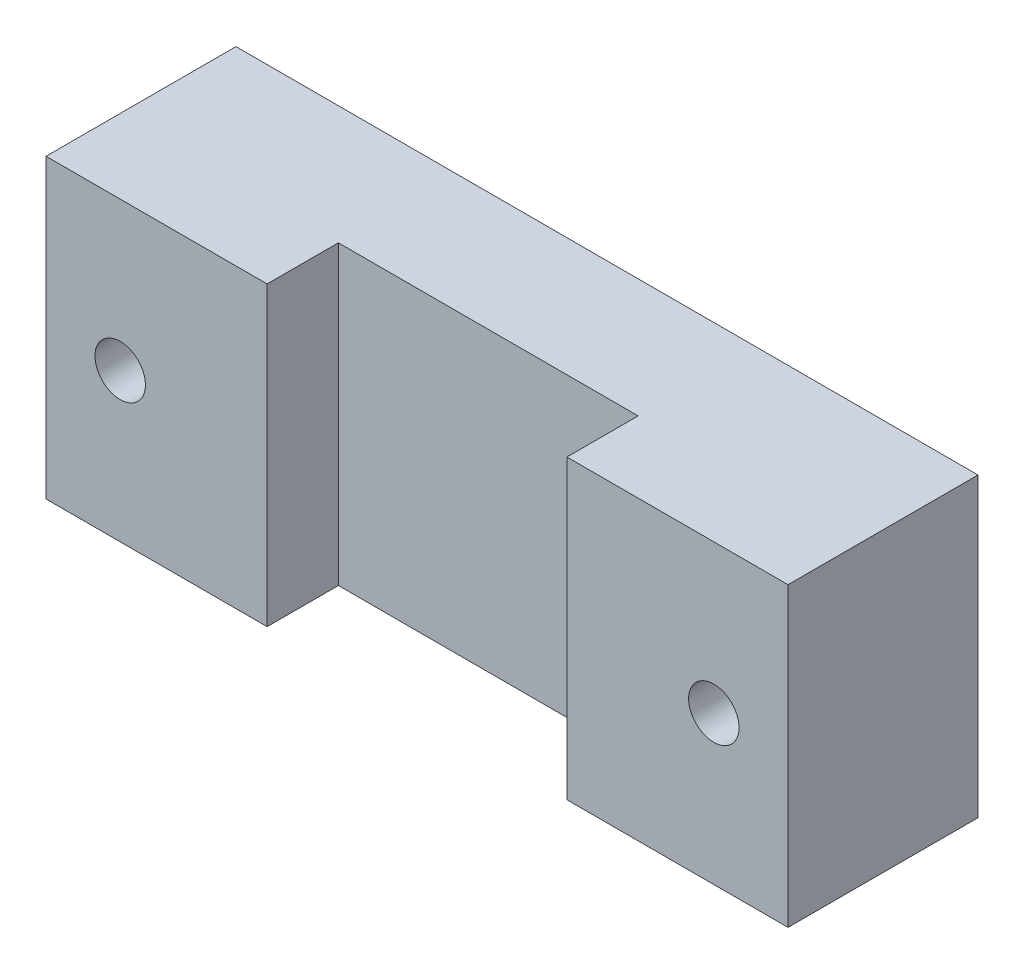
from build123d import *

# Parameters (mm, degrees)
SKETCH2_W           = 50
SKETCH2_H           = 20
SKETCH2_R           = 1.7
BOSS_EXTRUDE1_DEPTH = 8
BOSS_EXTRUDE2_DEPTH = 20
SKETCH6_R           = 3.75
CUT_EXTRUDE1_DEPTH  = 4
SKETCH7_R           = 1.7
CUT_EXTRUDE2_DEPTH  = 13.8


with BuildPart() as part:
    # Sketch2 → Boss-Extrude1 (new body)
    with BuildSketch(Plane.XY):
        Rectangle(SKETCH2_W, SKETCH2_H)
        with Locations((-20, 0)):
            Circle(SKETCH2_R, mode=Mode.SUBTRACT)
        with Locations((20, 0)):
            Circle(SKETCH2_R, mode=Mode.SUBTRACT)
    extrude(amount=BOSS_EXTRUDE1_DEPTH)

    # Sketch5 → Boss-Extrude2 (add)
    with BuildSketch(Plane.XZ.offset(10)):
        with BuildLine():
            Line((-25, 8), (-25, 12.8))
            Line((-25, 12.8), (-10.1, 12.8))
            Line((-10.1, 12.8), (-10.1, 8))
            Line((-10.1, 8), (10.1, 8))
            Line((10.1, 8), (10.1, 12.8))
            Line((10.1, 12.8), (25, 12.8))
            Line((25, 12.8), (25, 8))
            ThreePointArc((25, 8), (0, 0), (-25, 8))
        make_face()
    extrude(amount=-BOSS_EXTRUDE2_DEPTH)

    # Sketch6 → Cut-Extrude1 (cut)
    with BuildSketch(Plane(origin=(0, 0, 0), x_dir=(-1, 0, 0), z_dir=(0, 0, -1))):
        with Locations((20, 0)):
            Circle(SKETCH6_R)
        with Locations((-20, 0)):
            Circle(SKETCH6_R)
    extrude(amount=-CUT_EXTRUDE1_DEPTH, mode=Mode.SUBTRACT)

    # Sketch7 → Cut-Extrude2 (cut, through all)
    with BuildSketch(Plane(origin=(0, 0, 0), x_dir=(-1, 0, 0), z_dir=(0, 0, -1))):
        with Locations((20, 0)):
            Circle(SKETCH7_R)
        with Locations((-20, 0)):
            Circle(SKETCH7_R)
    extrude(amount=-CUT_EXTRUDE2_DEPTH, mode=Mode.SUBTRACT)


solid = part.part
